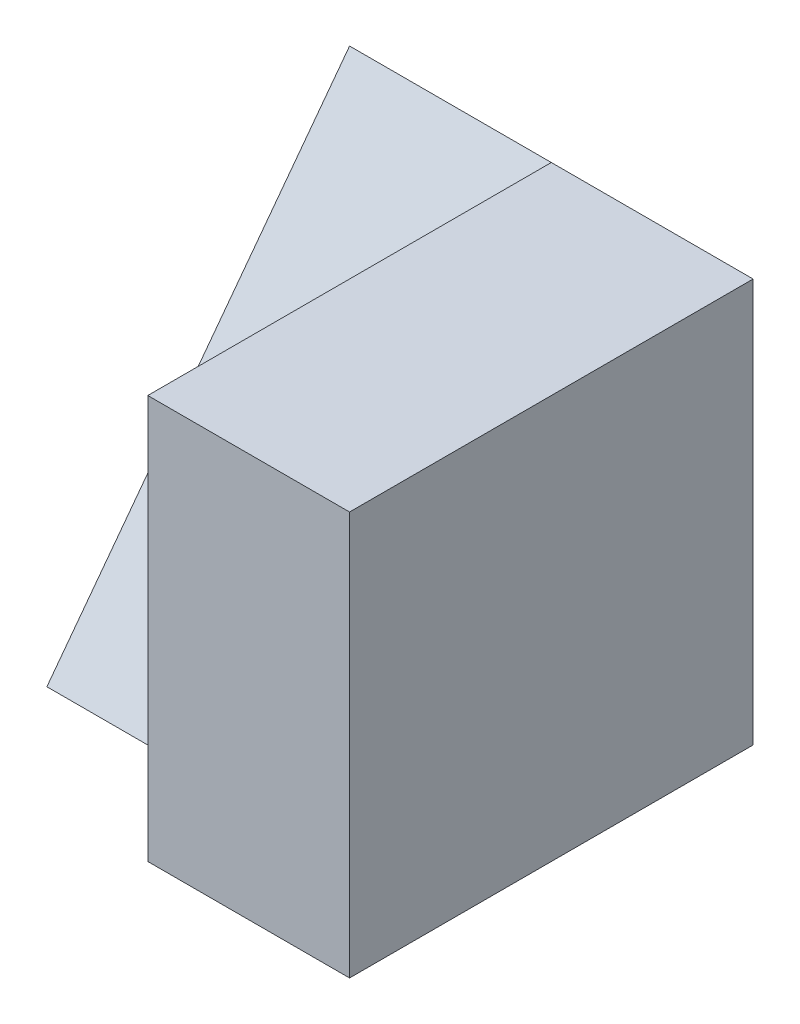
from build123d import *

# Parameters (mm, degrees)
SKETCH7_W           = 4
SKETCH7_H           = 4
BOSS_EXTRUDE6_DEPTH = 4
CUT_EXTRUDE2_DEPTH  = 2


with BuildPart() as part:
    # Sketch7 → Boss-Extrude6 (new body)
    with BuildSketch(Plane.XY):
        with Locations((2, 2)):
            Rectangle(SKETCH7_W, SKETCH7_H)
    extrude(amount=BOSS_EXTRUDE6_DEPTH)

    # Sketch8 → Cut-Extrude2 (cut)
    with BuildSketch(Plane.ZY):
        Polygon((0, 4), (3, 0), (4, 0), (4, 4), align=None)
    extrude(amount=-CUT_EXTRUDE2_DEPTH, mode=Mode.SUBTRACT)


solid = part.part
